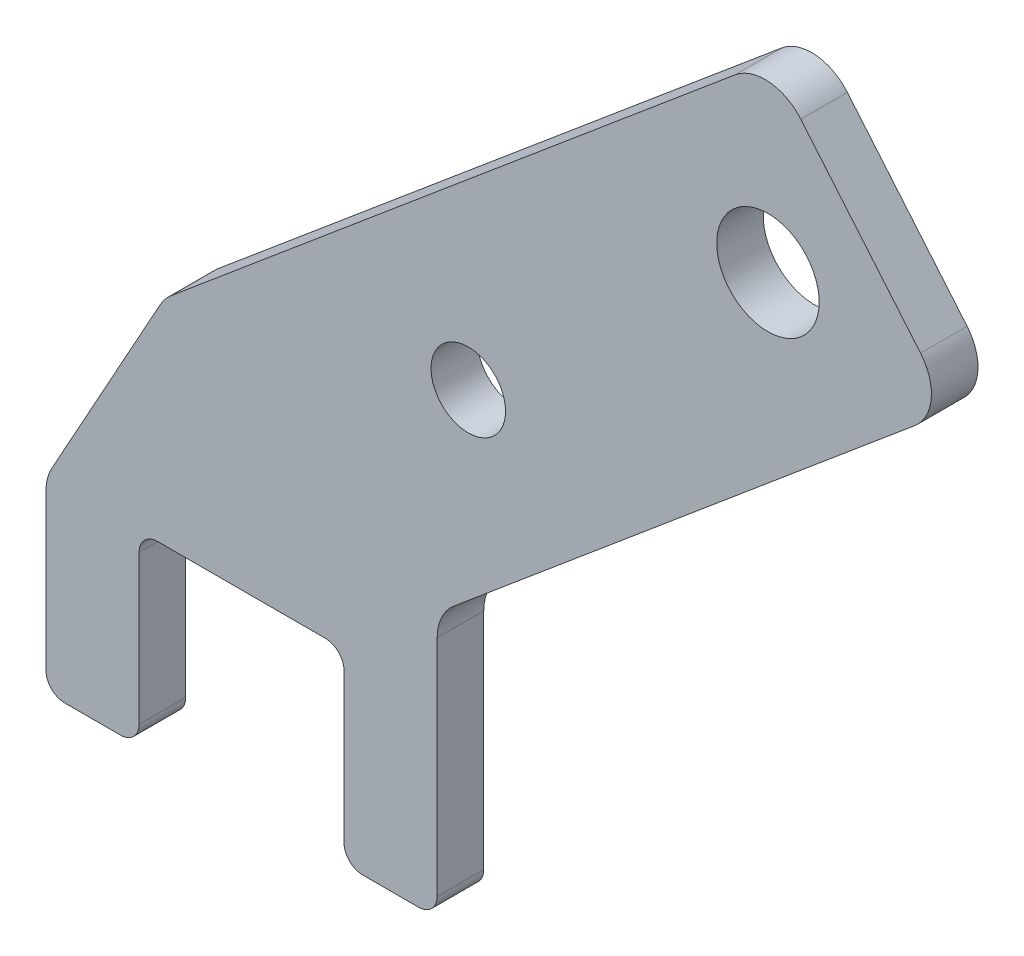
from build123d import *

# Parameters (mm, degrees)
ESQUISSE1_R        = 5.5
ESQUISSE1_R_2      = 4
BOSS_EXTRU_1_DEPTH = 5
CONG_1_R           = 5
CONG_2_R           = 2


with BuildPart() as part:
    # Esquisse1 → Boss.-Extru.1 (new body)
    with BuildSketch(Plane.XY):
        Polygon((34.397799289, 8.390996312), (89.511576954, 54.636946823), (70.227948663, 77.618280117), (5.114170998, 22.981333294), (-7.602200711, 0), (-7.602200711, -20), (2.397799289, -20), (2.397799289, 0), (24.397799289, 0), (24.397799289, -20), (34.397799289, -20), align=None)
        with Locations((69.911185048, 57.771374544)):
            Circle(ESQUISSE1_R, mode=Mode.SUBTRACT)
        with Locations((37.737318437, 30.774294937)):
            Circle(ESQUISSE1_R_2, mode=Mode.SUBTRACT)
    extrude(amount=BOSS_EXTRU_1_DEPTH)

    # Congé1
    cong_1_edges = [part.edges().sort_by_distance(p)[0] for p in [
        (-7.602200711, 0, 2.5),
        (5.114170998, 22.981333294, 2.5),
        (70.227948663, 77.618280117, 2.5),
        (89.511576954, 54.636946823, 2.5),
        (34.397799289, 8.390996312, 2.5),
    ]]
    fillet(cong_1_edges, radius=CONG_1_R)

    # Congé2
    cong_2_edges = [part.edges().sort_by_distance(p)[0] for p in [
        (2.397799289, 0, 2.5),
        (2.397799289, -20, 2.5),
        (-7.602200711, -20, 2.5),
        (34.397799289, -20, 2.5),
        (24.397799289, -20, 2.5),
        (24.397799289, 0, 2.5),
    ]]
    fillet(cong_2_edges, radius=CONG_2_R)


solid = part.part
